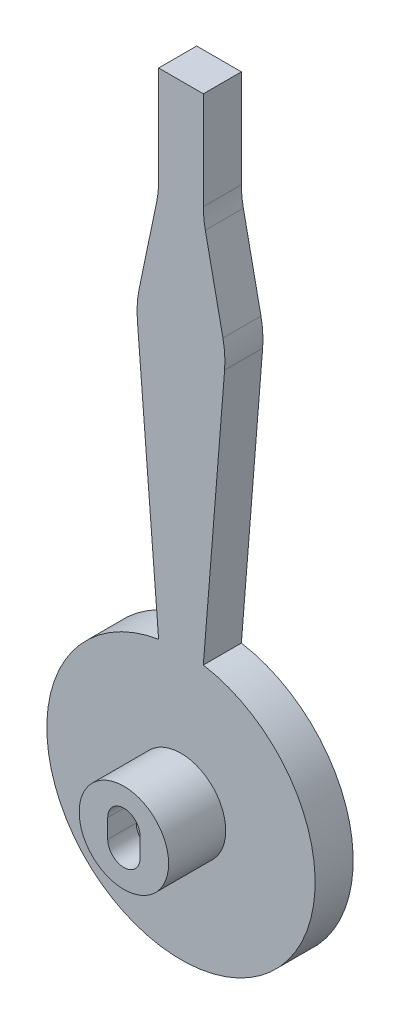
from build123d import *

# Parameters (mm, degrees)
SKETCH1_R           = 4.7
BOSS_EXTRUDE1_DEPTH = 4
SKETCH1_3_R         = 4.7
BOSS_EXTRUDE2_DEPTH = 10
CUT_EXTRUDE1_DEPTH  = 3


with BuildPart() as part:
    # Sketch1 → Boss-Extrude1 (new body)
    with BuildSketch(Plane.XY):
        with BuildLine():
            Line((2.35, 13.90278749), (4.585741176, 41.864603012))
            ThreePointArc((4.585741176, 41.864603012), (4.597967377, 43.28721197), (4.408193437, 44.697159337))
            Line((4.408193437, 44.697159337), (2.559360842, 53.589805153))
            ThreePointArc((2.559360842, 53.589805153), (2.402477907, 54.602201264), (2.35, 55.625335767))
            Line((2.35, 55.625335767), (2.35, 65.9))
            Line((2.35, 65.9), (-2.35, 65.9))
            Line((-2.35, 65.9), (-2.35, 55.625335767))
            ThreePointArc((-2.35, 55.625335767), (-2.402477907, 54.602201264), (-2.559360842, 53.589805153))
            Line((-2.559360842, 53.589805153), (-4.408193437, 44.697159337))
            ThreePointArc((-4.408193437, 44.697159337), (-4.597967377, 43.28721197), (-4.585741176, 41.864603012))
            Line((-4.585741176, 41.864603012), (-2.35, 13.90278749))
            ThreePointArc((-2.35, 13.90278749), (0, -14.1), (2.35, 13.90278749))
        make_face()
        Circle(SKETCH1_R, mode=Mode.SUBTRACT)
    extrude(amount=BOSS_EXTRUDE1_DEPTH)

    # Sketch1_3 → Boss-Extrude2 (add)
    with BuildSketch(Plane.XY):
        Circle(SKETCH1_3_R)
    extrude(amount=BOSS_EXTRUDE2_DEPTH)

    # Sketch2 → Cut-Extrude1 (cut)
    with BuildSketch(Plane.XY.offset(10)):
        with BuildLine():
            Line((1.7, 1), (1.7, -1))
            ThreePointArc((1.7, -1), (0, -2.7), (-1.7, -1))
            Line((-1.7, -1), (-1.7, 1))
            ThreePointArc((-1.7, 1), (0, 2.7), (1.7, 1))
        make_face()
    extrude(amount=-CUT_EXTRUDE1_DEPTH, mode=Mode.SUBTRACT)


solid = part.part
